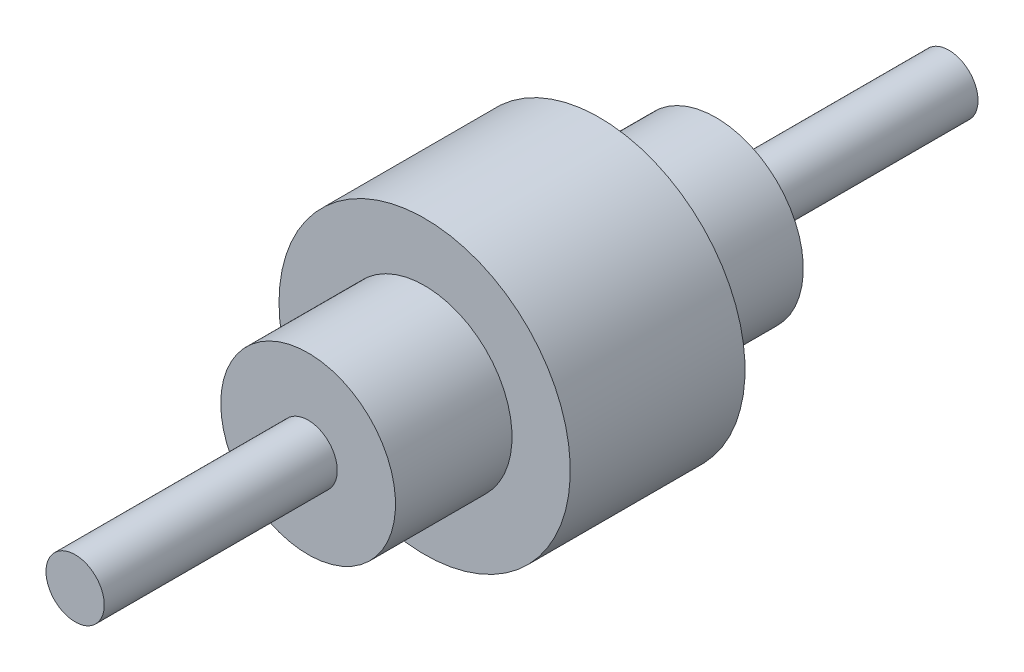
from build123d import *


with BuildPart() as part:
    # Croquis1 → Revolución1 (revolve)
    with BuildSketch(Plane(origin=(0, 0, 0), x_dir=(0, 0, -1), z_dir=(1, 0, 0))):
        Polygon((-150, 0), (-150, 10), (-70, 10), (-70, 30), (-30, 30), (-30, 50), (30, 50), (30, 30), (70, 30), (70, 10), (150, 10), (150, 0), align=None)
    revolve(axis=Axis((0, 0, -150), (0, 0, 1)))


solid = part.part
